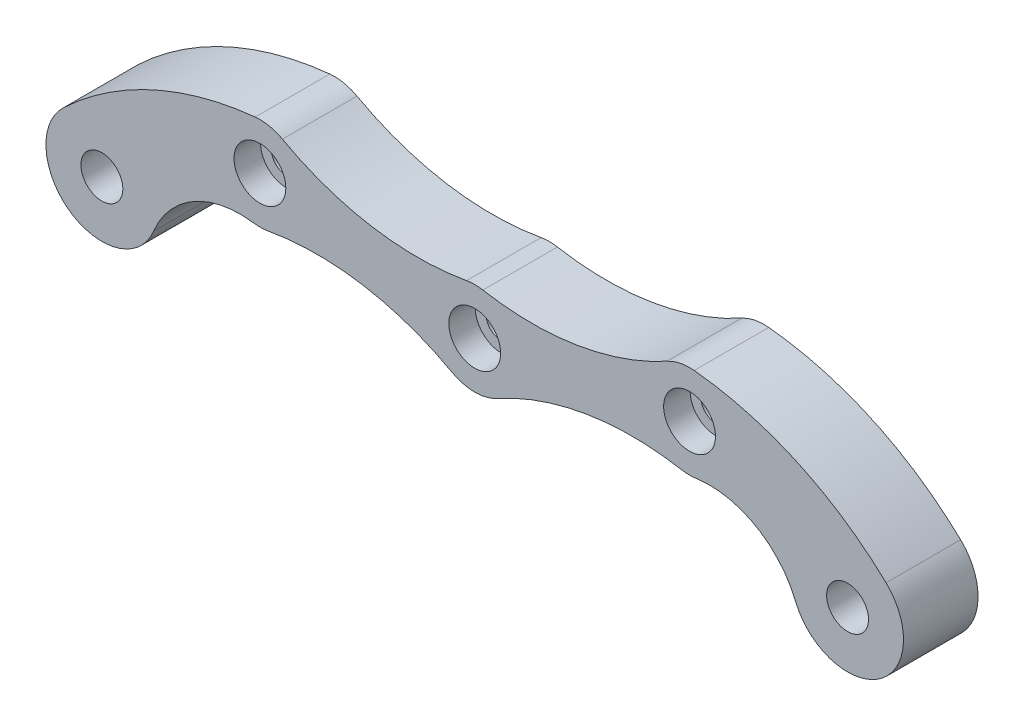
from build123d import *

# Parameters (mm, degrees)
BOSS_EXTRUDE1_DEPTH                            = 4
CBORE_FOR_4_SOCKET_HEAD_CAP_SCREW1_D           = 3.2639
CBORE_FOR_4_SOCKET_HEAD_CAP_SCREW1_DEPTH       = 9.019425513
CBORE_FOR_4_SOCKET_HEAD_CAP_SCREW1_CBORE_D     = 5.55752
CBORE_FOR_4_SOCKET_HEAD_CAP_SCREW1_CBORE_DEPTH = 2.8448
CBORE_FOR_4_SOCKET_HEAD_CAP_SCREW1_TIP         = 0.980574487
CBORE_FOR_8_SOCKET_HEAD_CAP_SCREW1_D           = 4.4958
CBORE_FOR_8_SOCKET_HEAD_CAP_SCREW1_DEPTH       = 8.649325414
CBORE_FOR_8_SOCKET_HEAD_CAP_SCREW1_CBORE_D     = 7.9375
CBORE_FOR_8_SOCKET_HEAD_CAP_SCREW1_CBORE_DEPTH = 4.1656
CBORE_FOR_8_SOCKET_HEAD_CAP_SCREW1_TIP         = 1.350674586


with BuildPart() as part:
    # Sketch1 → Boss-Extrude1 (new body, symmetric)
    with BuildSketch(Plane.XY):
        with BuildLine():
            ThreePointArc((-44.12938743, -0.647051637), (-43.384473284, -9.954325443), (-34.443470177, -7.263841056))
            ThreePointArc((-34.443470177, -7.263841056), (-30.155368055, -2.36099743), (-23.757529046, -1.138969828))
            ThreePointArc((-23.757529046, -1.138969828), (-22.961581659, -1.18930409), (-22.167756654, -1.112442901))
            ThreePointArc((-22.167756654, -1.112442901), (-12.010862121, -1.048885846), (-2.414899511, -4.378157187))
            ThreePointArc((-2.414899511, -4.378157187), (0, -5), (2.414899511, -4.378157187))
            ThreePointArc((2.414899511, -4.378157187), (12.010862121, -1.048885846), (22.167756654, -1.112442901))
            ThreePointArc((22.167756654, -1.112442901), (22.961581659, -1.18930409), (23.757529046, -1.138969828))
            ThreePointArc((23.757529046, -1.138969828), (30.155368055, -2.36099743), (34.443470177, -7.263841056))
            ThreePointArc((34.443470177, -7.263841056), (43.384473284, -9.954325443), (44.12938743, -0.647051637))
            ThreePointArc((44.12938743, -0.647051637), (34.621269329, 5.779365543), (23.545617652, 8.78487507))
            ThreePointArc((23.545617652, 8.78487507), (22.042434881, 8.708455183), (20.630100489, 8.188157187))
            ThreePointArc((20.630100489, 8.188157187), (11.034137879, 4.858885846), (0.877243346, 4.922442901))
            ThreePointArc((0.877243346, 4.922442901), (0, 5), (-0.877243346, 4.922442901))
            ThreePointArc((-0.877243346, 4.922442901), (-11.034137879, 4.858885846), (-20.630100489, 8.188157187))
            ThreePointArc((-20.630100489, 8.188157187), (-22.042434881, 8.708455183), (-23.545617652, 8.78487507))
            ThreePointArc((-23.545617652, 8.78487507), (-34.621269329, 5.779365543), (-44.12938743, -0.647051637))
        make_face()
    extrude(amount=BOSS_EXTRUDE1_DEPTH, both=True)

    # CBORE for #4 Socket Head Cap Screw1
    with Locations(Plane.XY.offset(4)):
        with Locations((-23.045, 3.81), (0, 0), (23.045, 3.81)):
            CounterBoreHole(CBORE_FOR_4_SOCKET_HEAD_CAP_SCREW1_D / 2, CBORE_FOR_4_SOCKET_HEAD_CAP_SCREW1_CBORE_D / 2, CBORE_FOR_4_SOCKET_HEAD_CAP_SCREW1_CBORE_DEPTH, depth=CBORE_FOR_4_SOCKET_HEAD_CAP_SCREW1_DEPTH)
            with Locations((0, 0, -(CBORE_FOR_4_SOCKET_HEAD_CAP_SCREW1_DEPTH + CBORE_FOR_4_SOCKET_HEAD_CAP_SCREW1_TIP / 2))):  # 118° drill point
                Cone(0, CBORE_FOR_4_SOCKET_HEAD_CAP_SCREW1_D / 2, CBORE_FOR_4_SOCKET_HEAD_CAP_SCREW1_TIP, mode=Mode.SUBTRACT)

    # CBORE for #8 Socket Head Cap Screw1
    with Locations(Plane(origin=(0, 0, -4), x_dir=(-1, 0, 0), z_dir=(0, 0, -1))):
        with Locations((-40, -5), (40, -5)):
            CounterBoreHole(CBORE_FOR_8_SOCKET_HEAD_CAP_SCREW1_D / 2, CBORE_FOR_8_SOCKET_HEAD_CAP_SCREW1_CBORE_D / 2, CBORE_FOR_8_SOCKET_HEAD_CAP_SCREW1_CBORE_DEPTH, depth=CBORE_FOR_8_SOCKET_HEAD_CAP_SCREW1_DEPTH)
            with Locations((0, 0, -(CBORE_FOR_8_SOCKET_HEAD_CAP_SCREW1_DEPTH + CBORE_FOR_8_SOCKET_HEAD_CAP_SCREW1_TIP / 2))):  # 118° drill point
                Cone(0, CBORE_FOR_8_SOCKET_HEAD_CAP_SCREW1_D / 2, CBORE_FOR_8_SOCKET_HEAD_CAP_SCREW1_TIP, mode=Mode.SUBTRACT)


solid = part.part
